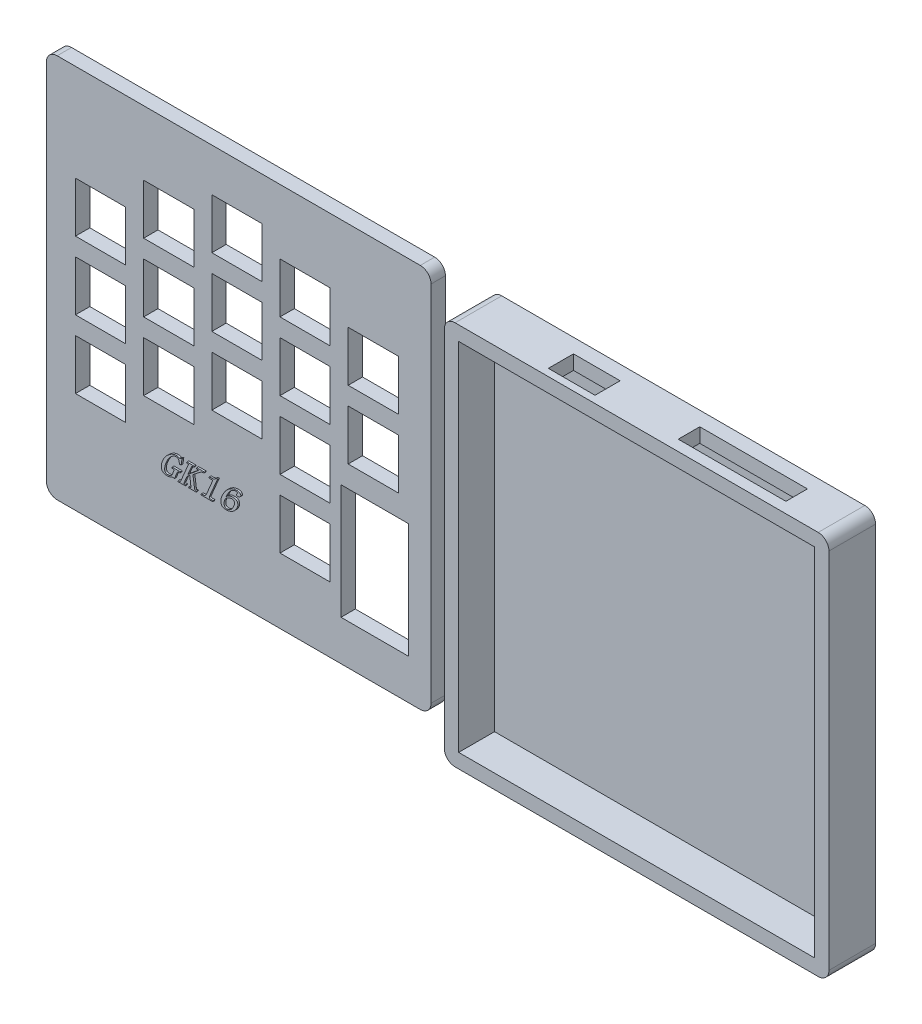
from build123d import *

# Parameters (mm, degrees)
MODEL_W             = 107.2
MODEL_H             = 107.2
MODEL_W_2           = 14
MODEL_H_2           = 14
MODEL_W_3           = 18.820040736
MODEL_H_3           = 32
EXTRUDE_1_DEPTH     = 4
SKETCH_3_W          = 107.2
SKETCH_3_H          = 107.2
EXTRUDE_2_DEPTH     = 13
SKETCH_6_W          = 99.2
SKETCH_6_H          = 99.2
CUT_EXTRUDE_1_DEPTH = 10
SKETCH_9_W          = 30
SKETCH_9_H          = 6
SKETCH_9_W_2        = 13
SKETCH_9_H_2        = 7
CUT_EXTRUDE_2_DEPTH = 4
FILLET_1_R          = 3
FILLET_2_R          = 3
EXTRUDE_3_DEPTH     = 0.5


with BuildPart() as part:
    # Model → 凸台-拉伸1 (new body)
    with BuildSketch(Plane.XY):
        with Locations((53.6, 53.6)):
            Rectangle(MODEL_W, MODEL_H)
        with Locations((15.101038404, 54.213715528)):
            Rectangle(MODEL_W_2, MODEL_H_2, mode=Mode.SUBTRACT)
        with Locations((15.101038404, 35.213715528)):
            Rectangle(MODEL_W_2, MODEL_H_2, mode=Mode.SUBTRACT)
        with Locations((15.101038404, 73.213715528)):
            Rectangle(MODEL_W_2, MODEL_H_2, mode=Mode.SUBTRACT)
        with Locations((53.101038404, 50.213715528)):
            Rectangle(MODEL_W_2, MODEL_H_2, mode=Mode.SUBTRACT)
        with Locations((34.101038404, 44.213715528)):
            Rectangle(MODEL_W_2, MODEL_H_2, mode=Mode.SUBTRACT)
        with Locations((72.101038404, 25.213715528)):
            Rectangle(MODEL_W_2, MODEL_H_2, mode=Mode.SUBTRACT)
        with Locations((91.101038404, 56.213715528)):
            Rectangle(MODEL_W_2, MODEL_H_2, mode=Mode.SUBTRACT)
        with Locations((34.101038404, 63.213715528)):
            Rectangle(MODEL_W_2, MODEL_H_2, mode=Mode.SUBTRACT)
        with Locations((34.101038404, 82.213715528)):
            Rectangle(MODEL_W_2, MODEL_H_2, mode=Mode.SUBTRACT)
        with Locations((53.101038404, 69.213715528)):
            Rectangle(MODEL_W_2, MODEL_H_2, mode=Mode.SUBTRACT)
        with Locations((53.101038404, 88.213715528)):
            Rectangle(MODEL_W_2, MODEL_H_2, mode=Mode.SUBTRACT)
        with Locations((72.101038404, 44.213715528)):
            Rectangle(MODEL_W_2, MODEL_H_2, mode=Mode.SUBTRACT)
        with Locations((72.101038404, 63.213715528)):
            Rectangle(MODEL_W_2, MODEL_H_2, mode=Mode.SUBTRACT)
        with Locations((72.101038404, 82.213715528)):
            Rectangle(MODEL_W_2, MODEL_H_2, mode=Mode.SUBTRACT)
        with Locations((91.101038404, 75.213715528)):
            Rectangle(MODEL_W_2, MODEL_H_2, mode=Mode.SUBTRACT)
        with Locations((91.511058772, 27.213715528)):
            Rectangle(MODEL_W_3, MODEL_H_3, mode=Mode.SUBTRACT)
    extrude(amount=EXTRUDE_1_DEPTH)

    # 圆角1
    fillet_1_edges = [part.edges().sort_by_distance(p)[0] for p in [
        (0, 107.2, 2),
        (107.2, 107.2, 2),
        (107.2, 0, 2),
        (0, 0, 2),
    ]]
    fillet(fillet_1_edges, radius=FILLET_1_R)

    # 草图10 → 凸台-拉伸3 (add)
    with BuildSketch(Plane.XY.offset(4)):
        with BuildLine():
            add(Edge.make_bspline(
                [(36.5931233, 27.49449553), (36.547152805, 27.492444275), (36.45159848, 27.488180534), (36.305341104, 27.453630142), (36.151886344, 27.39844209), (35.989652409, 27.323607281), (35.820398695, 27.226118155), (35.642522185, 27.108461916), (35.456704396, 26.969247825), (35.263193317, 26.809778143), (35.067993815, 26.626956554), (34.878027917, 26.417785329), (34.693101982, 26.184567445), (34.513012531, 25.92681342), (34.338995944, 25.643765762), (34.169461208, 25.336630707), (34.006185779, 25.004106873), (33.904718008, 24.771875963), (33.852541108, 24.652457859)],
                knots=[0, 0, 0, 0, 0.000137798, 0.000286427, 0.000448492, 0.000626627, 0.0008216, 0.00103389, 0.001266083, 0.001517828, 0.001785842, 0.00206764, 0.002364678, 0.002678203, 0.003010364, 0.003361001, 0.003730304, 0.00412123, 0.00412123, 0.00412123, 0.00412123], degree=3))
            add(Edge.make_bspline(
                [(33.852541108, 24.652457859), (33.819204287, 24.571430829), (33.753615858, 24.412014439), (33.670681214, 24.171767486), (33.600753687, 23.936620354), (33.545560054, 23.705886393), (33.502548732, 23.47971919), (33.474176329, 23.257558425), (33.460102389, 23.040104028), (33.458823575, 22.831016161), (33.475439182, 22.636041312), (33.517916281, 22.462541728), (33.586749113, 22.315264814), (33.679234339, 22.192463155), (33.80016116, 22.099798623), (33.944351699, 22.03346455), (34.112423992, 21.993667737), (34.232449774, 21.989722277), (34.295606176, 21.987646215)],
                knots=[0, 0, 0, 0, 0.000262803, 0.000517052, 0.000762087, 0.000998507, 0.001228473, 0.001452437, 0.001669934, 0.001881835, 0.002079267, 0.002255564, 0.002414692, 0.002563935, 0.002712164, 0.002866712, 0.003037096, 0.003226317, 0.003226317, 0.003226317, 0.003226317], degree=3))
            add(Edge.make_bspline(
                [(34.295606176, 21.987646215), (34.366751719, 21.989254539), (34.503602979, 21.992348213), (34.701000992, 22.019220726), (34.8813176, 22.065617265), (35.046522795, 22.127933093), (35.193600847, 22.209878405), (35.32108781, 22.310596546), (35.43202189, 22.426631904), (35.48764059, 22.517329341), (35.515640423, 22.562988681)],
                knots=[0, 0, 0, 0, 0.000213374, 0.000410434, 0.000596078, 0.000770896, 0.000938793, 0.001098851, 0.001256954, 0.001417238, 0.001417238, 0.001417238, 0.001417238], degree=3))
            Line((35.515640423, 22.562988681), (36.029339053, 23.775317448))
            add(Edge.make_bspline(
                [(36.029339053, 23.775317448), (36.039744821, 23.802421943), (36.058871602, 23.852242557), (36.071367298, 23.924624808), (36.068128706, 23.987648976), (36.043327044, 24.039655143), (36.000454609, 24.080847309), (35.937689013, 24.106496562), (35.858115141, 24.122897084), (35.798714692, 24.12401701), (35.766068505, 24.124632516)],
                knots=[0, 0, 0, 0, 8.6912e-05, 0.000159753, 0.000219051, 0.000273051, 0.000328452, 0.000393392, 0.000473491, 0.000571229, 0.000571229, 0.000571229, 0.000571229], degree=3))
            Line((35.766068505, 24.124632516), (35.437301382, 24.124632516))
            Line((35.437301382, 24.124632516), (35.576000012, 24.45339964))
            Line((35.576000012, 24.45339964), (37.877369875, 24.45339964))
            Line((37.877369875, 24.45339964), (37.738671245, 24.124632516))
            Line((37.738671245, 24.124632516), (37.368808231, 24.124632516))
            add(Edge.make_bspline(
                [(37.368808231, 24.124632516), (37.3279952, 24.12103568), (37.245101005, 24.113730247), (37.149117616, 24.066926224), (37.078217472, 24.014991832), (37.031458663, 23.961059033), (36.988122923, 23.897521697), (36.965719726, 23.849334304), (36.953996587, 23.824118818)],
                knots=[0, 0, 0, 0, 0.000122051, 0.000247894, 0.000313905, 0.000384829, 0.000460698, 0.000543976, 0.000543976, 0.000543976, 0.000543976], degree=3))
            Line((36.953996587, 23.824118818), (36.182164396, 22.001772927))
            add(Edge.make_bspline(
                [(36.182164396, 22.001772927), (36.143640745, 22.007806246), (36.074729097, 22.018598732), (35.984282715, 22.032250623), (35.919427935, 22.043089201), (35.867619314, 22.055572288), (35.816003317, 22.068678128), (35.776029953, 22.069432097), (35.754510286, 22.069837996)],
                knots=[0, 0, 0, 0, 0.000116972, 0.000209242, 0.000274486, 0.000314048, 0.000369211, 0.000433539, 0.000433539, 0.000433539, 0.000433539], degree=3))
            add(Edge.make_bspline(
                [(35.754510286, 22.069837996), (35.735665693, 22.069286736), (35.698669197, 22.068204478), (35.641538991, 22.061068989), (35.578906625, 22.039267307), (35.537084273, 22.016264346), (35.51307193, 22.003057174)],
                knots=[0, 0, 0, 0, 5.6565e-05, 0.000111051, 0.000171968, 0.0002541, 0.0002541, 0.0002541, 0.0002541], degree=3))
            add(Edge.make_bspline(
                [(35.51307193, 22.003057174), (35.453922086, 21.972785853), (35.338066444, 21.913494008), (35.16224343, 21.838945326), (34.989046045, 21.77980158), (34.818482444, 21.732674001), (34.647059207, 21.699383432), (34.472898308, 21.676556373), (34.294139734, 21.662003216), (34.173202636, 21.659929328), (34.111958916, 21.658879092)],
                knots=[0, 0, 0, 0, 0.000199294, 0.000390354, 0.0005723, 0.000748012, 0.00092079, 0.001095697, 0.001274766, 0.001458485, 0.001458485, 0.001458485, 0.001458485], degree=3))
            add(Edge.make_bspline(
                [(34.111958916, 21.658879092), (34.059295476, 21.659749764), (33.956435507, 21.661450323), (33.806212522, 21.670856254), (33.66443421, 21.690799071), (33.531068496, 21.716225041), (33.405633518, 21.747442833), (33.290024948, 21.78904459), (33.182838192, 21.836886361), (33.082807549, 21.890021678), (32.993156586, 21.954064161), (32.910018966, 22.023002685), (32.836822786, 22.100551811), (32.771962233, 22.184949493), (32.715139622, 22.276358851), (32.667474329, 22.375867305), (32.629428565, 22.482857012), (32.58827156, 22.634718722), (32.556329335, 22.833193033), (32.534781944, 23.077061742), (32.536496064, 23.326820963), (32.560496021, 23.582193619), (32.603876307, 23.843379066), (32.670872385, 24.10983277), (32.755932652, 24.382810655), (32.828965527, 24.563041098), (32.866239738, 24.655026352)],
                knots=[0, 0, 0, 0, 0.000158009, 0.000308617, 0.000451192, 0.0005872, 0.000715843, 0.000838514, 0.000955218, 0.001067859, 0.001177593, 0.001285132, 0.001391415, 0.001496731, 0.001604002, 0.001713713, 0.001827055, 0.001944196, 0.00218531, 0.002428901, 0.002678048, 0.002933377, 0.00319771, 0.003471499, 0.003757032, 0.004054667, 0.004054667, 0.004054667, 0.004054667], degree=3))
            add(Edge.make_bspline(
                [(32.866239738, 24.655026352), (32.913787067, 24.761788517), (33.008481151, 24.974413403), (33.172498394, 25.28191835), (33.354317692, 25.577661951), (33.551898619, 25.863508088), (33.768272547, 26.137398831), (34.002337636, 26.39995862), (34.255058871, 26.650148349), (34.520205006, 26.888477433), (34.794398569, 27.105930781), (35.07093144, 27.297551042), (35.348070971, 27.458649931), (35.623947625, 27.592301966), (35.900362487, 27.694214983), (36.17537358, 27.767806603), (36.449760612, 27.815584234), (36.633174473, 27.820717453), (36.72411645, 27.823262653)],
                knots=[0, 0, 0, 0, 0.000350531, 0.000698109, 0.001044573, 0.001391557, 0.001739948, 0.002091043, 0.002446111, 0.002806273, 0.003160075, 0.003495283, 0.003814671, 0.004120834, 0.004413791, 0.004696961, 0.004974174, 0.005246801, 0.005246801, 0.005246801, 0.005246801], degree=3))
            add(Edge.make_bspline(
                [(36.72411645, 27.823262653), (36.771693237, 27.821979202), (36.868079416, 27.819379047), (37.012493426, 27.799522537), (37.158033978, 27.767002315), (37.297778325, 27.723206652), (37.422301778, 27.677495545), (37.524046135, 27.648302835), (37.594077625, 27.626256317), (37.631595801, 27.620951556), (37.644921245, 27.619067448)],
                knots=[0, 0, 0, 0, 0.000142696, 0.000289089, 0.000436464, 0.000589613, 0.000728103, 0.000834137, 0.000907351, 0.000947677, 0.000947677, 0.000947677, 0.000947677], degree=3))
            add(Edge.make_bspline(
                [(37.644921245, 27.619067448), (37.683209167, 27.621683616), (37.763957299, 27.62720104), (37.867768118, 27.656417389), (37.963331586, 27.691746916), (38.056168448, 27.728601584), (38.169460564, 27.771315172), (38.25075979, 27.805023438), (38.294750012, 27.823262653)],
                knots=[0, 0, 0, 0, 0.000114881, 0.00024228, 0.000321499, 0.00042071, 0.000541866, 0.000684718, 0.000684718, 0.000684718, 0.000684718], degree=3))
            Line((38.294750012, 27.823262653), (38.041753437, 26.201259229))
            Line((38.041753437, 26.201259229), (37.525486313, 26.097235256))
            add(Edge.make_bspline(
                [(37.525486313, 26.097235256), (37.528564398, 26.158861441), (37.534482971, 26.27735691), (37.534866827, 26.448386095), (37.526293906, 26.605393664), (37.508685182, 26.74838325), (37.482396973, 26.877073437), (37.446374119, 26.991665628), (37.40164047, 27.092142344), (37.348864006, 27.179995325), (37.285485613, 27.254816101), (37.213498857, 27.31889944), (37.132363705, 27.373830234), (37.042133574, 27.418728734), (36.942413242, 27.453356548), (36.833828706, 27.477532462), (36.716344857, 27.491446723), (36.635113194, 27.493456596), (36.5931233, 27.49449553)],
                knots=[0, 0, 0, 0, 0.000185092, 0.000355897, 0.000512833, 0.000656513, 0.000787739, 0.000906336, 0.001016129, 0.001117006, 0.001212706, 0.001309119, 0.001405292, 0.0015058, 0.00161059, 0.001721192, 0.001838909, 0.00196487, 0.00196487, 0.00196487, 0.00196487], degree=3))
        make_face()
        with BuildLine():
            Line((42.236102752, 21.741070873), (40.14791782, 21.741070873))
            Line((40.14791782, 21.741070873), (40.287900697, 22.069837996))
            Line((40.287900697, 22.069837996), (40.495948642, 22.069837996))
            add(Edge.make_bspline(
                [(40.495948642, 22.069837996), (40.525579582, 22.070496086), (40.579856924, 22.071701562), (40.654298209, 22.088194811), (40.713773739, 22.11619338), (40.760022342, 22.156537682), (40.788199804, 22.212790403), (40.79515771, 22.283064977), (40.786578657, 22.366706909), (40.768928188, 22.425396863), (40.75921919, 22.457680462)],
                knots=[0, 0, 0, 0, 8.8762e-05, 0.000162592, 0.00022692, 0.000284195, 0.000343354, 0.000410737, 0.000493289, 0.000594215, 0.000594215, 0.000594215, 0.000594215], degree=3))
            Line((40.75921919, 22.457680462), (40.465126724, 24.9182969))
            Line((40.465126724, 24.9182969), (39.674030834, 24.232509229))
            Line((39.674030834, 24.232509229), (38.841839053, 22.265043475))
            add(Edge.make_bspline(
                [(38.841839053, 22.265043475), (38.834560318, 22.246348433), (38.821699939, 22.213317237), (38.809974242, 22.167750879), (38.809176622, 22.131347009), (38.826797222, 22.095439408), (38.876395245, 22.073585709), (38.917596418, 22.071185456), (38.940726039, 22.069837996)],
                knots=[0, 0, 0, 0, 6.0127e-05, 0.000106235, 0.000140933, 0.000166778, 0.000221415, 0.000291345, 0.000291345, 0.000291345, 0.000291345], degree=3))
            Line((38.940726039, 22.069837996), (39.334989738, 22.069837996))
            Line((39.334989738, 22.069837996), (39.195006861, 21.741070873))
            Line((39.195006861, 21.741070873), (37.140212341, 21.741070873))
            Line((37.140212341, 21.741070873), (37.280195218, 22.069837996))
            Line((37.280195218, 22.069837996), (37.592267135, 22.069837996))
            add(Edge.make_bspline(
                [(37.592267135, 22.069837996), (37.617133777, 22.07013113), (37.663633382, 22.070679277), (37.727359279, 22.079601119), (37.780624816, 22.093005463), (37.837336019, 22.121009365), (37.894320551, 22.178183638), (37.922678768, 22.234927517), (37.937729464, 22.265043475)],
                knots=[0, 0, 0, 0, 7.4531e-05, 0.000139369, 0.000192646, 0.000238593, 0.000327605, 0.000428277, 0.000428277, 0.000428277, 0.000428277], degree=3))
            Line((37.937729464, 22.265043475), (40.033619875, 27.21709827))
            add(Edge.make_bspline(
                [(40.033619875, 27.21709827), (40.039648044, 27.232336953), (40.050803876, 27.26053792), (40.059556966, 27.301542586), (40.057353321, 27.336660555), (40.045731809, 27.367204947), (40.017072739, 27.388935962), (39.975766169, 27.403358308), (39.919194599, 27.411607744), (39.876539029, 27.41205316), (39.852541108, 27.412303749)],
                knots=[0, 0, 0, 0, 4.9155e-05, 9.0967e-05, 0.000124456, 0.000153798, 0.000185698, 0.000228388, 0.000284338, 0.000356301, 0.000356301, 0.000356301, 0.000356301], degree=3))
            Line((39.852541108, 27.412303749), (39.54046919, 27.412303749))
            Line((39.54046919, 27.412303749), (39.67916782, 27.741070873))
            Line((39.67916782, 27.741070873), (41.733962341, 27.741070873))
            Line((41.733962341, 27.741070873), (41.595263711, 27.412303749))
            Line((41.595263711, 27.412303749), (41.201000012, 27.412303749))
            add(Edge.make_bspline(
                [(41.201000012, 27.412303749), (41.175482958, 27.410708183), (41.124923117, 27.407546707), (41.064999442, 27.38273884), (41.021221923, 27.351879403), (40.990959088, 27.317743366), (40.961814843, 27.274393526), (40.947006869, 27.240519844), (40.939013711, 27.222235256)],
                knots=[0, 0, 0, 0, 7.6302e-05, 0.000151186, 0.000190748, 0.000236189, 0.000287124, 0.000346866, 0.000346866, 0.000346866, 0.000346866], degree=3))
            Line((40.939013711, 27.222235256), (39.924458916, 24.8245469))
            Line((39.924458916, 24.8245469), (42.5931233, 27.061704434))
            add(Edge.make_bspline(
                [(42.5931233, 27.061704434), (42.614669685, 27.0769209), (42.655386574, 27.105675939), (42.710317847, 27.14889855), (42.755577707, 27.188998084), (42.791818918, 27.224408637), (42.818438933, 27.256399011), (42.834423423, 27.285109711), (42.842968886, 27.310931025), (42.836929518, 27.342529118), (42.804755027, 27.375796491), (42.743068546, 27.397051886), (42.657477035, 27.410116051), (42.591912916, 27.411510228), (42.554595903, 27.412303749)],
                knots=[0, 0, 0, 0, 7.9125e-05, 0.000149524, 0.000209569, 0.000260422, 0.000301538, 0.000333721, 0.000358953, 0.000381122, 0.000426672, 0.000489404, 0.000574067, 0.000685914, 0.000685914, 0.000685914, 0.000685914], degree=3))
            Line((42.554595903, 27.412303749), (42.305452067, 27.412303749))
            Line((42.305452067, 27.412303749), (42.444150697, 27.741070873))
            Line((42.444150697, 27.741070873), (44.528482889, 27.741070873))
            Line((44.528482889, 27.741070873), (44.389784259, 27.412303749))
            Line((44.389784259, 27.412303749), (44.140640423, 27.412303749))
            add(Edge.make_bspline(
                [(44.140640423, 27.412303749), (44.113594065, 27.411300211), (44.056464919, 27.40918047), (43.968007949, 27.390877714), (43.871789749, 27.363651059), (43.768968669, 27.324901863), (43.658759429, 27.275970467), (43.544373323, 27.214006772), (43.423914531, 27.141631214), (43.34372468, 27.087357362), (43.302027409, 27.059135941)],
                knots=[0, 0, 0, 0, 8.107e-05, 0.000171242, 0.000270029, 0.000380959, 0.000500532, 0.000631525, 0.000770941, 0.000921964, 0.000921964, 0.000921964, 0.000921964], degree=3))
            Line((43.302027409, 27.059135941), (41.331993163, 25.52574553))
            Line((41.331993163, 25.52574553), (41.780195218, 22.410163338))
            add(Edge.make_bspline(
                [(41.780195218, 22.410163338), (41.786753901, 22.377458129), (41.798745743, 22.317660203), (41.825188058, 22.237666993), (41.857736961, 22.176229566), (41.895761243, 22.133024863), (41.934373127, 22.107903484), (41.962759338, 22.087471498), (41.98379098, 22.073718511), (41.996294953, 22.070912912), (42.001085629, 22.069837996)],
                knots=[0, 0, 0, 0, 0.000100015, 0.000182866, 0.000251846, 0.000307307, 0.000353289, 0.000389271, 0.000412847, 0.000427489, 0.000427489, 0.000427489, 0.000427489], degree=3))
            Line((42.001085629, 22.069837996), (42.376085629, 22.069837996))
            Line((42.376085629, 22.069837996), (42.236102752, 21.741070873))
        make_face()
        with BuildLine():
            Line((48.179595903, 27.823262653), (45.942438368, 22.536019503))
            add(Edge.make_bspline(
                [(45.942438368, 22.536019503), (45.927472335, 22.496700251), (45.900670921, 22.4262867), (45.886279927, 22.323179426), (45.900720262, 22.235395837), (45.951276314, 22.167499609), (46.029173575, 22.123526748), (46.127629886, 22.090824553), (46.250895456, 22.072775386), (46.340502488, 22.070874408), (46.389356176, 22.069837996)],
                knots=[0, 0, 0, 0, 0.000125895, 0.000225456, 0.000309326, 0.000385617, 0.000470426, 0.000573582, 0.000695829, 0.000842374, 0.000842374, 0.000842374, 0.000842374], degree=3))
            Line((46.389356176, 22.069837996), (46.978825355, 22.069837996))
            Line((46.978825355, 22.069837996), (46.838842478, 21.741070873))
            Line((46.838842478, 21.741070873), (43.551171245, 21.741070873))
            Line((43.551171245, 21.741070873), (43.691154122, 22.069837996))
            Line((43.691154122, 22.069837996), (44.143208916, 22.069837996))
            add(Edge.make_bspline(
                [(44.143208916, 22.069837996), (44.203219372, 22.071238349), (44.316829928, 22.073889469), (44.476192624, 22.095387298), (44.614771968, 22.129879822), (44.732014071, 22.182527871), (44.832256222, 22.24908148), (44.916468277, 22.331343617), (44.987290256, 22.42778213), (45.021919132, 22.500267026), (45.039613026, 22.537303749)],
                knots=[0, 0, 0, 0, 0.00017996, 0.000340696, 0.000481495, 0.000606806, 0.000724348, 0.000840599, 0.000958246, 0.001081165, 0.001081165, 0.001081165, 0.001081165], degree=3))
            Line((45.039613026, 22.537303749), (46.797746587, 26.691841421))
            add(Edge.make_bspline(
                [(46.797746587, 26.691841421), (46.803044107, 26.707063119), (46.813004878, 26.735684031), (46.81834076, 26.779642907), (46.808206442, 26.819591181), (46.788922296, 26.856057064), (46.754068947, 26.885810703), (46.703905709, 26.905532424), (46.639518004, 26.917798019), (46.59147883, 26.918675077), (46.565297957, 26.919153064)],
                knots=[0, 0, 0, 0, 4.8343e-05, 9.0898e-05, 0.00013046, 0.000170127, 0.000212894, 0.000264664, 0.000330148, 0.000408581, 0.000408581, 0.000408581, 0.000408581], degree=3))
            Line((46.565297957, 26.919153064), (45.743380149, 26.919153064))
            Line((45.743380149, 26.919153064), (45.882078779, 27.247920188))
            Line((45.882078779, 27.247920188), (46.334133574, 27.247920188))
            add(Edge.make_bspline(
                [(46.334133574, 27.247920188), (46.410814569, 27.249787228), (46.559017171, 27.253395686), (46.773335444, 27.277015503), (46.970480619, 27.31985245), (47.154339931, 27.377279784), (47.326670397, 27.457899014), (47.492246918, 27.558373797), (47.653312546, 27.680140617), (47.752423635, 27.774707717), (47.803311656, 27.823262653)],
                knots=[0, 0, 0, 0, 0.000230056, 0.000444633, 0.000645641, 0.000834495, 0.001021241, 0.001214839, 0.001414671, 0.001625545, 0.001625545, 0.001625545, 0.001625545], degree=3))
            Line((47.803311656, 27.823262653), (48.179595903, 27.823262653))
        make_face()
        with BuildLine():
            add(Edge.make_bspline(
                [(52.416325355, 25.604084571), (52.504151343, 25.602509147), (52.67127204, 25.599511333), (52.908794109, 25.573191719), (53.119135251, 25.527842467), (53.302484295, 25.464528903), (53.458191334, 25.38192948), (53.587473962, 25.281111466), (53.687514045, 25.158883306), (53.757104387, 25.019546401), (53.804184645, 24.872019275), (53.83736839, 24.720595357), (53.851501416, 24.565919696), (53.854185421, 24.408013506), (53.83603877, 24.247247023), (53.804163147, 24.083384403), (53.754760326, 23.916837137), (53.711280074, 23.807108908), (53.689013711, 23.750916763)],
                knots=[0, 0, 0, 0, 0.000263424, 0.000501259, 0.000715636, 0.000907763, 0.001081289, 0.001242143, 0.001396386, 0.001550891, 0.001706433, 0.001860082, 0.00201496, 0.002171644, 0.00233304, 0.00249927, 0.002671976, 0.00285325, 0.00285325, 0.00285325, 0.00285325], degree=3))
            add(Edge.make_bspline(
                [(53.689013711, 23.750916763), (53.65178553, 23.666385597), (53.578477753, 23.499931269), (53.447498158, 23.26416491), (53.303666822, 23.044781722), (53.147975218, 22.839593338), (52.976353378, 22.652901261), (52.793970903, 22.479172036), (52.59619585, 22.323423574), (52.386727899, 22.184651578), (52.170185667, 22.062934508), (51.953707944, 21.953714021), (51.735879347, 21.864588024), (51.51902469, 21.788521248), (51.301206564, 21.731070655), (51.08314209, 21.690270721), (50.86566354, 21.662671629), (50.72034656, 21.660140603), (50.64791782, 21.658879092)],
                knots=[0, 0, 0, 0, 0.000276981, 0.000545416, 0.000807934, 0.001063512, 0.001317146, 0.001567887, 0.001818397, 0.00207129, 0.0023209, 0.002563269, 0.002798188, 0.003026437, 0.003252278, 0.003473172, 0.003691724, 0.003908899, 0.003908899, 0.003908899, 0.003908899], degree=3))
            add(Edge.make_bspline(
                [(50.64791782, 21.658879092), (50.555784494, 21.661045014), (50.379847017, 21.665181052), (50.128876074, 21.697596955), (49.904945227, 21.755099779), (49.707357695, 21.834436899), (49.535294798, 21.936163859), (49.392163401, 22.064072576), (49.275389641, 22.214407739), (49.1877931, 22.388138637), (49.12753875, 22.582560587), (49.096503697, 22.797297365), (49.092374053, 23.030936913), (49.115598686, 23.284199252), (49.165188609, 23.557418901), (49.243766493, 23.850072814), (49.347854046, 24.162782655), (49.434304022, 24.374262976), (49.479253437, 24.484221558)],
                knots=[0, 0, 0, 0, 0.000276355, 0.000527726, 0.000757294, 0.000968114, 0.001164574, 0.001353773, 0.001540524, 0.001732359, 0.001934231, 0.00214855, 0.002381055, 0.002633713, 0.002910312, 0.003213089, 0.003542042, 0.003898332, 0.003898332, 0.003898332, 0.003898332], degree=3))
            add(Edge.make_bspline(
                [(49.479253437, 24.484221558), (49.536314903, 24.615108316), (49.648331751, 24.872050928), (49.840534005, 25.238132326), (50.041235796, 25.583288748), (50.255531355, 25.904989444), (50.48385274, 26.202704631), (50.72345729, 26.47785554), (50.976506073, 26.729972028), (51.241229332, 26.957478463), (51.51449228, 27.16072177), (51.793583649, 27.337128387), (52.077100393, 27.487311739), (52.365434747, 27.60965504), (52.658378998, 27.705488785), (52.955717995, 27.773837962), (53.258089245, 27.814549528), (53.46115278, 27.820349272), (53.563157546, 27.823262653)],
                knots=[0, 0, 0, 0, 0.000428225, 0.000840644, 0.001239532, 0.001625638, 0.001999373, 0.002364346, 0.002719414, 0.003070022, 0.003410609, 0.003740183, 0.004059586, 0.00437206, 0.004678683, 0.004983052, 0.005286191, 0.005592168, 0.005592168, 0.005592168, 0.005592168], degree=3))
            add(Edge.make_bspline(
                [(53.563157546, 27.823262653), (53.615418735, 27.822256894), (53.716288467, 27.820315671), (53.861357618, 27.806111762), (53.994740278, 27.783650346), (54.116232211, 27.750446548), (54.225706779, 27.70696849), (54.322983252, 27.654272469), (54.408253951, 27.592124301), (54.478814432, 27.520135354), (54.538214683, 27.445846491), (54.589049587, 27.374359482), (54.628072494, 27.304723379), (54.655891176, 27.237542908), (54.671318032, 27.172903933), (54.677319357, 27.110946916), (54.671188887, 27.051439937), (54.658465998, 27.014436117), (54.652198642, 26.996207859)],
                knots=[0, 0, 0, 0, 0.000156762, 0.000302568, 0.00043685, 0.000562102, 0.000679672, 0.000789443, 0.000893213, 0.00099492, 0.001090793, 0.001178432, 0.001257765, 0.001329786, 0.001395822, 0.0014564, 0.001515823, 0.001573514, 0.001573514, 0.001573514, 0.001573514], degree=3))
            add(Edge.make_bspline(
                [(54.652198642, 26.996207859), (54.636069537, 26.961826998), (54.603973621, 26.89341122), (54.538193824, 26.800920722), (54.462225641, 26.71584694), (54.371417239, 26.642460348), (54.266431067, 26.580186358), (54.14271751, 26.538665756), (54.002590576, 26.512861971), (53.903181758, 26.509804406), (53.850828779, 26.50819416)],
                knots=[0, 0, 0, 0, 0.000113719, 0.000226294, 0.00033903, 0.000454962, 0.000575229, 0.000703171, 0.000844228, 0.001001164, 0.001001164, 0.001001164, 0.001001164], degree=3))
            add(Edge.make_bspline(
                [(53.850828779, 26.50819416), (53.815659456, 26.509707966), (53.751024974, 26.512490052), (53.662438082, 26.531144919), (53.593492978, 26.568319826), (53.542190586, 26.619825504), (53.516925406, 26.688394806), (53.510865584, 26.76773914), (53.528559537, 26.859015864), (53.552629667, 26.921250554), (53.565726039, 26.955111968)],
                knots=[0, 0, 0, 0, 0.00010559, 0.000194054, 0.000268772, 0.000337812, 0.00040697, 0.000483013, 0.000574221, 0.000683072, 0.000683072, 0.000683072, 0.000683072], degree=3))
            add(Edge.make_bspline(
                [(53.565726039, 26.955111968), (53.578817041, 26.98284811), (53.604649197, 27.037579166), (53.652587357, 27.111491295), (53.699812491, 27.178412094), (53.721313539, 27.225734218), (53.731393848, 27.247920188)],
                knots=[0, 0, 0, 0, 9.1893e-05, 0.000181331, 0.000263973, 0.000336915, 0.000336915, 0.000336915, 0.000336915], degree=3))
            add(Edge.make_bspline(
                [(53.731393848, 27.247920188), (53.736931575, 27.264399616), (53.747254394, 27.295118742), (53.749712082, 27.343269572), (53.734469022, 27.387111405), (53.703618337, 27.427949371), (53.648507893, 27.461392916), (53.565360642, 27.479606275), (53.454512297, 27.493960831), (53.370174825, 27.494303737), (53.323003437, 27.49449553)],
                knots=[0, 0, 0, 0, 5.204e-05, 9.7007e-05, 0.000141679, 0.000188427, 0.000247919, 0.000330481, 0.000441826, 0.000583146, 0.000583146, 0.000583146, 0.000583146], degree=3))
            add(Edge.make_bspline(
                [(53.323003437, 27.49449553), (53.269824461, 27.493104802), (53.162485271, 27.490297684), (53.000947002, 27.464120928), (52.837702079, 27.424412849), (52.672558224, 27.368918545), (52.506193233, 27.296142175), (52.33796233, 27.206959978), (52.167535457, 27.102439133), (51.991656703, 26.982932749), (51.816007519, 26.832395833), (51.639196595, 26.645606022), (51.463824455, 26.418185228), (51.284752686, 26.153691102), (51.106373765, 25.850016059), (50.92494021, 25.508001742), (50.742012474, 25.127369779), (50.625151188, 24.857928882), (50.564441793, 24.717954434)],
                knots=[0, 0, 0, 0, 0.000159433, 0.000321808, 0.000489695, 0.000663107, 0.000843711, 0.001033858, 0.001233846, 0.00144332, 0.00167107, 0.001926325, 0.002213549, 0.002531633, 0.002884032, 0.003269532, 0.003692863, 0.004150552, 0.004150552, 0.004150552, 0.004150552], degree=3))
            add(Edge.make_bspline(
                [(50.564441793, 24.717954434), (50.582977855, 24.75263352), (50.620341404, 24.822536921), (50.689940805, 24.919833274), (50.771243083, 25.010144884), (50.860329949, 25.09703973), (50.963428941, 25.175143219), (51.076217845, 25.248299415), (51.199970493, 25.315145672), (51.377331369, 25.394092261), (51.604475754, 25.477578064), (51.878892035, 25.549330409), (52.148890485, 25.596018647), (52.327959144, 25.601419417), (52.416325355, 25.604084571)],
                knots=[0, 0, 0, 0, 0.000117878, 0.00023761, 0.000357699, 0.000482138, 0.000610319, 0.000744969, 0.000885181, 0.001031748, 0.001327117, 0.001609957, 0.001881893, 0.002146825, 0.002146825, 0.002146825, 0.002146825], degree=3))
        make_face()
        with BuildLine():
            add(Edge.make_bspline(
                [(50.312729464, 24.12334827), (50.277920743, 24.038963258), (50.211046252, 23.87684283), (50.130496212, 23.637286539), (50.067415201, 23.414242681), (50.026551309, 23.206288769), (50.001053147, 23.014505756), (49.999807134, 22.837748926), (50.016859955, 22.676666521), (50.053729144, 22.531640051), (50.108669675, 22.404456707), (50.172223849, 22.292749112), (50.247636756, 22.198126524), (50.335297064, 22.121263175), (50.433454937, 22.060027542), (50.54318064, 22.01733478), (50.663545668, 21.992962909), (50.74711933, 21.989462096), (50.79046919, 21.987646215)],
                knots=[0, 0, 0, 0, 0.000273774, 0.000525974, 0.000757779, 0.000968587, 0.001161331, 0.001337278, 0.001497536, 0.001646115, 0.001784224, 0.001911979, 0.002030715, 0.002145366, 0.002260124, 0.002376027, 0.002496671, 0.002626691, 0.002626691, 0.002626691, 0.002626691], degree=3))
            add(Edge.make_bspline(
                [(50.79046919, 21.987646215), (50.840629785, 21.988312886), (50.939577977, 21.989627981), (51.085209631, 22.009707049), (51.227488219, 22.035010012), (51.364495427, 22.075941931), (51.498349793, 22.125392596), (51.626034417, 22.189659592), (51.752126122, 22.261061045), (51.87374143, 22.347084356), (51.993837386, 22.447885543), (52.109090755, 22.570741566), (52.225003975, 22.711697554), (52.337256301, 22.875181156), (52.450747457, 23.057090761), (52.560110924, 23.26136781), (52.671435116, 23.484211715), (52.739461676, 23.642246515), (52.774630149, 23.723947585)],
                knots=[0, 0, 0, 0, 0.000150345, 0.000296574, 0.000440392, 0.000583458, 0.0007249, 0.000867913, 0.001011755, 0.001159259, 0.001314158, 0.001481288, 0.001663814, 0.001861187, 0.002075729, 0.002306751, 0.002556014, 0.002822803, 0.002822803, 0.002822803, 0.002822803], degree=3))
            add(Edge.make_bspline(
                [(52.774630149, 23.723947585), (52.796248183, 23.777644099), (52.837689356, 23.88057883), (52.887169288, 24.032633465), (52.921323314, 24.175601876), (52.939556636, 24.309440523), (52.94395345, 24.43385851), (52.934665141, 24.548952755), (52.908664318, 24.654606776), (52.868558813, 24.749978816), (52.817243643, 24.835421844), (52.755066376, 24.9089144), (52.684548779, 24.971517992), (52.605685442, 25.02419171), (52.515522601, 25.062005423), (52.41763603, 25.089890755), (52.310896211, 25.109075254), (52.236620601, 25.110298105), (52.198003437, 25.110933886)],
                knots=[0, 0, 0, 0, 0.00017362, 0.000332826, 0.000479235, 0.000614002, 0.00073735, 0.000852108, 0.000959256, 0.001062293, 0.001161405, 0.001257105, 0.001349891, 0.00144357, 0.001540197, 0.001641806, 0.001748639, 0.001864335, 0.001864335, 0.001864335, 0.001864335], degree=3))
            add(Edge.make_bspline(
                [(52.198003437, 25.110933886), (52.128509907, 25.108240858), (51.986865812, 25.102751835), (51.772636406, 25.06402878), (51.554405112, 24.999268237), (51.369315468, 24.928484976), (51.218683152, 24.853972204), (51.10052284, 24.78544192), (50.978144846, 24.705572387), (50.852182553, 24.612852848), (50.723318673, 24.506665303), (50.587755091, 24.39190323), (50.4503516, 24.26274696), (50.359516688, 24.170739466), (50.312729464, 24.12334827)],
                knots=[0, 0, 0, 0, 0.000208444, 0.000424858, 0.000650834, 0.000890751, 0.001018254, 0.001154608, 0.001300295, 0.001456467, 0.001623543, 0.001801145, 0.001989229, 0.002189011, 0.002189011, 0.002189011, 0.002189011], degree=3))
        make_face(mode=Mode.SUBTRACT)
    extrude(amount=EXTRUDE_3_DEPTH)


with BuildPart() as body_2:
    # 草图3 → 凸台-拉伸2 (new body)
    with BuildSketch(Plane.XY):
        with Locations((173.495754075, 53.6)):
            Rectangle(SKETCH_3_W, SKETCH_3_H)
    extrude(amount=EXTRUDE_2_DEPTH)

    # 草图6 → 切除-拉伸1 (cut)
    with BuildSketch(Plane.XY.offset(13)):
        with Locations((173.495754075, 53.6)):
            Rectangle(SKETCH_6_W, SKETCH_6_H)
    extrude(amount=-CUT_EXTRUDE_1_DEPTH, mode=Mode.SUBTRACT)

    # 草图9 → 切除-拉伸2 (cut)
    with BuildSketch(Plane(origin=(0, 107.2, 0), x_dir=(1, 0, 0), z_dir=(0, 1, 0))):
        with Locations((197.095754075, -7)):
            Rectangle(SKETCH_9_W, SKETCH_9_H)
        with Locations((153.395754075, -7.5)):
            Rectangle(SKETCH_9_W_2, SKETCH_9_H_2)
    extrude(amount=-CUT_EXTRUDE_2_DEPTH, mode=Mode.SUBTRACT)

    # 圆角2
    fillet_2_edges = [body_2.edges().sort_by_distance(p)[0] for p in [
        (119.895754075, 0, 6.5),
        (119.895754075, 107.2, 6.5),
        (227.095754075, 107.2, 6.5),
        (227.095754075, 0, 6.5),
    ]]
    fillet(fillet_2_edges, radius=FILLET_2_R)


solid = Compound([part.part, body_2.part])
